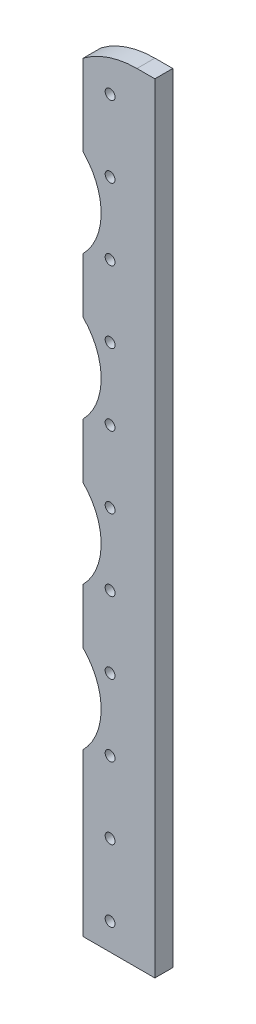
from build123d import *

# Parameters (mm, degrees)
SKETCH1_W           = 25.4
SKETCH1_H           = 276.225
BOSS_EXTRUDE1_DEPTH = 6.35
CUT_EXTRUDE1_DEPTH  = 7.35
SKETCH3_R           = 1.75
CUT_EXTRUDE2_DEPTH  = 7.35
LPATTERN1_COUNT     = 11
LPATTERN1_PITCH     = 25.4
SKETCH4_R           = 22.225
CUT_EXTRUDE3_DEPTH  = 7.35
LPATTERN2_COUNT     = 4
LPATTERN2_PITCH     = 50.8


with BuildPart() as part:
    # Sketch1 → Boss-Extrude1 (new body)
    with BuildSketch(Plane.XY):
        with Locations((-12.7, 138.1125)):
            Rectangle(SKETCH1_W, SKETCH1_H)
    extrude(amount=BOSS_EXTRUDE1_DEPTH)

    # Sketch2 → Cut-Extrude1 (cut, through all)
    with BuildSketch(Plane.XY.offset(6.35)):
        with BuildLine():
            Line((-6.35, 276.225), (-31.763279736, 276.225))
            Line((-31.763279736, 276.225), (-31.763279736, 263.507280815))
            ThreePointArc((-31.763279736, 263.507280815), (-20.55893353, 272.86811022), (-6.35, 276.225))
        make_face()
    extrude(amount=-CUT_EXTRUDE1_DEPTH, mode=Mode.SUBTRACT)

    # Sketch3 → Cut-Extrude2 (cut, through all)
    with BuildSketch(Plane.XY.offset(6.35)):
        with Locations((-15.875, 263.525)):
            Circle(SKETCH3_R)
    cut_extrude2 = extrude(amount=-CUT_EXTRUDE2_DEPTH, mode=Mode.SUBTRACT)

    # LPattern1: Cut-Extrude2 ×11
    with Locations(*[(0, -i * LPATTERN1_PITCH, 0) for i in range(1, LPATTERN1_COUNT)]):
        add(cut_extrude2, mode=Mode.SUBTRACT)

    # Sketch4 → Cut-Extrude3 (cut, through all)
    with BuildSketch(Plane.XY.offset(6.35)):
        with Locations((-41.275, 225.425)):
            Circle(SKETCH4_R)
    cut_extrude3 = extrude(amount=-CUT_EXTRUDE3_DEPTH, mode=Mode.SUBTRACT)

    # LPattern2: Cut-Extrude3 ×4
    with Locations(*[(0, -i * LPATTERN2_PITCH, 0) for i in range(1, LPATTERN2_COUNT)]):
        add(cut_extrude3, mode=Mode.SUBTRACT)


solid = part.part
